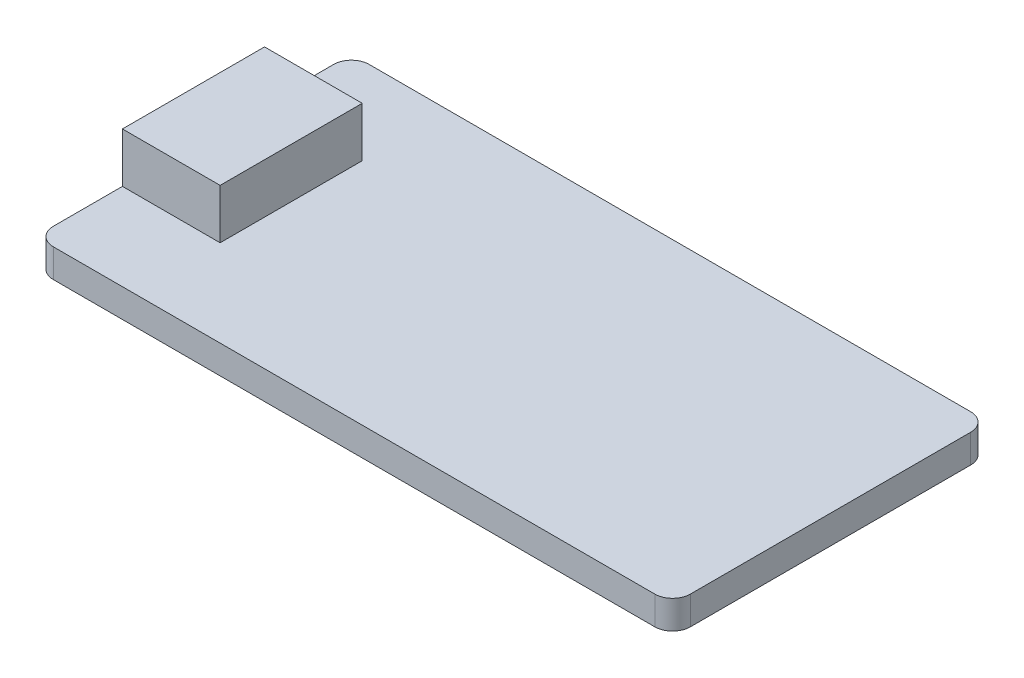
from build123d import *

# Parameters (mm, degrees)
SKETCH1_W           = 35.86
SKETCH1_H           = 17.78
BOSS_EXTRUDE1_DEPTH = 1.6
SKETCH2_W           = 5.5
SKETCH2_H           = 8
BOSS_EXTRUDE2_DEPTH = 2.8
FILLET1_R           = 1


with BuildPart() as part:
    # Sketch1 → Boss-Extrude1 (new body)
    with BuildSketch(Plane(origin=(0, 0, 0), x_dir=(1, 0, 0), z_dir=(0, 1, 0))):
        with Locations((17.93, 8.89)):
            Rectangle(SKETCH1_W, SKETCH1_H)
    extrude(amount=BOSS_EXTRUDE1_DEPTH)

    # Sketch2 → Boss-Extrude2 (add)
    with BuildSketch(Plane(origin=(0, 1.6, 0), x_dir=(1, 0, 0), z_dir=(0, 1, 0))):
        with Locations((2.75, 8.89)):
            Rectangle(SKETCH2_W, SKETCH2_H)
    extrude(amount=BOSS_EXTRUDE2_DEPTH)

    # Fillet1
    fillet1_edges = [part.edges().sort_by_distance(p)[0] for p in [
        (0, 0.8, -17.78),
        (35.86, 0.8, -17.78),
        (35.86, 0.8, 0),
        (0, 0.8, 0),
    ]]
    fillet(fillet1_edges, radius=FILLET1_R)


solid = part.part
